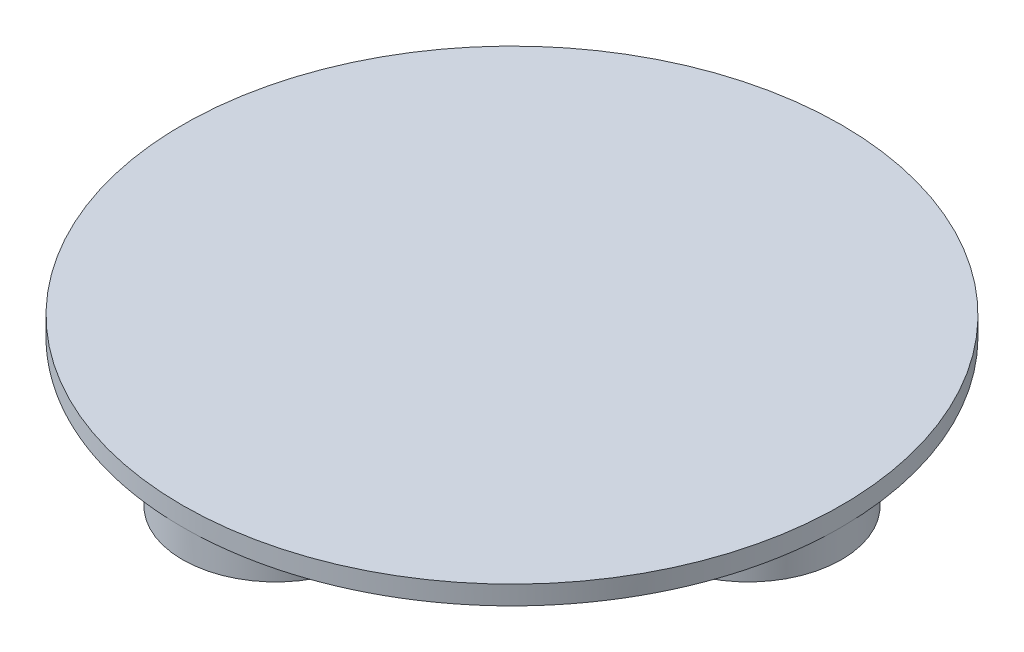
from build123d import *

# Parameters (mm, degrees)
SKETCH1_R           = 35
BOSS_EXTRUDE1_DEPTH = 2
SKETCH3_R           = 9.9
BOSS_EXTRUDE2_DEPTH = 3


with BuildPart() as part:
    # Sketch1 → Boss-Extrude1 (new body)
    with BuildSketch(Plane(origin=(0, 0, 0), x_dir=(1, 0, 0), z_dir=(0, 1, 0))):
        Circle(SKETCH1_R)
    extrude(amount=BOSS_EXTRUDE1_DEPTH)

    # Sketch3 → Boss-Extrude2 (add)
    with BuildSketch(Plane.XZ):
        with Locations((25.1, 0)):
            Circle(SKETCH3_R)
        with Locations((0, -25.1)):
            Circle(SKETCH3_R)
        with Locations((-25.1, 0)):
            Circle(SKETCH3_R)
        with Locations((0, 25.1)):
            Circle(SKETCH3_R)
    extrude(amount=BOSS_EXTRUDE2_DEPTH)


solid = part.part
